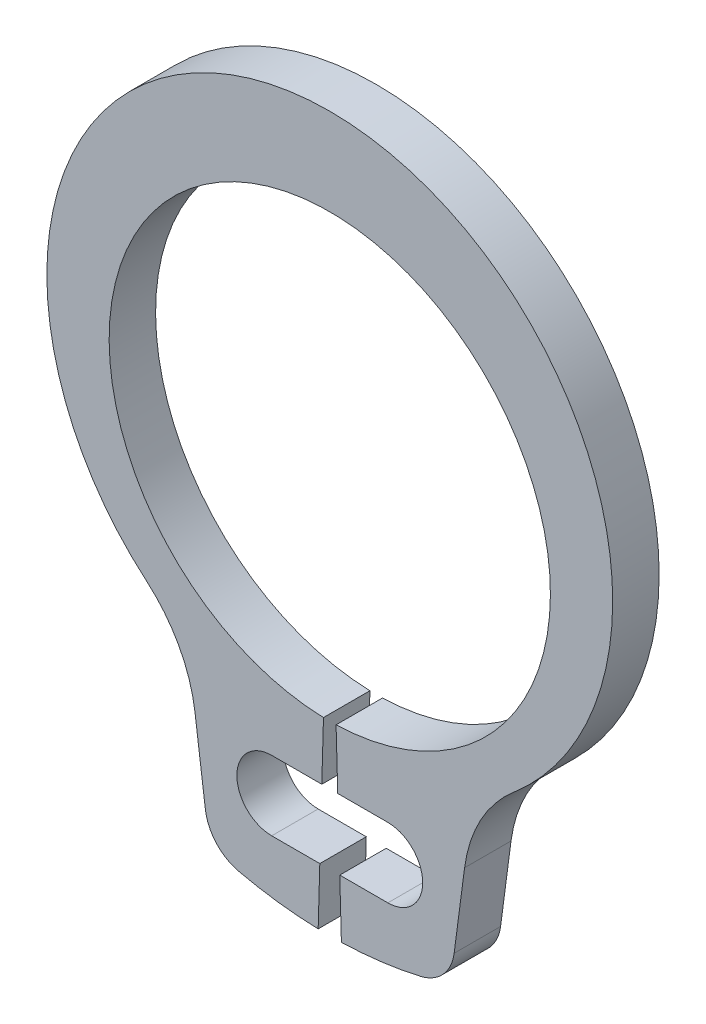
from build123d import *

# Parameters (mm, degrees)
BODYSKE_R   = 0.6
BODY_DEPTH  = 0.8
NOTSKE_W    = 2
NOTSKE_H    = 1.2
NOTCH_DEPTH = 1.8


with BuildPart() as part:
    # BodySke → Body (new body)
    with BuildSketch(Plane.XY):
        with BuildLine():
            Line((0.108571429, -3.798448663), (0.2, -6.997142274))
            ThreePointArc((0.2, -6.997142274), (0.887407187, -6.943522772), (1.566204647, -6.822536405))
            ThreePointArc((1.566204647, -6.822536405), (1.953248067, -6.596169328), (2.141980652, -6.189445006))
            Line((2.141980652, -6.189445006), (2.321707775, -4.824281977))
            ThreePointArc((2.321707775, -4.824281977), (2.597941642, -3.974889916), (3.160591953, -3.281206522))
            ThreePointArc((3.160591953, -3.281206522), (0, 5.3), (-3.160591953, -3.281206522))
            ThreePointArc((-3.160591953, -3.281206522), (-2.597941642, -3.974889916), (-2.321707775, -4.824281977))
            Line((-2.321707775, -4.824281977), (-2.141980652, -6.189445006))
            ThreePointArc((-2.141980652, -6.189445006), (-1.953248067, -6.596169328), (-1.566204647, -6.822536405))
            ThreePointArc((-1.566204647, -6.822536405), (-0.887407187, -6.943522772), (-0.2, -6.997142274))
            Line((-0.2, -6.997142274), (-0.108571429, -3.798448663))
            ThreePointArc((-0.108571429, -3.798448663), (0, 3.8), (0.108571429, -3.798448663))
        make_face()
        with Locations((1, -5.408326913)):
            Circle(BODYSKE_R, mode=Mode.SUBTRACT)
        with Locations((-1, -5.408326913)):
            Circle(BODYSKE_R, mode=Mode.SUBTRACT)
    extrude(amount=-BODY_DEPTH)

    # NotSke → Notch (cut, through all)
    with BuildSketch(Plane.XY):
        with Locations((0, -5.408326913)):
            Rectangle(NOTSKE_W, NOTSKE_H)
    extrude(amount=-NOTCH_DEPTH, mode=Mode.SUBTRACT)


solid = part.part
